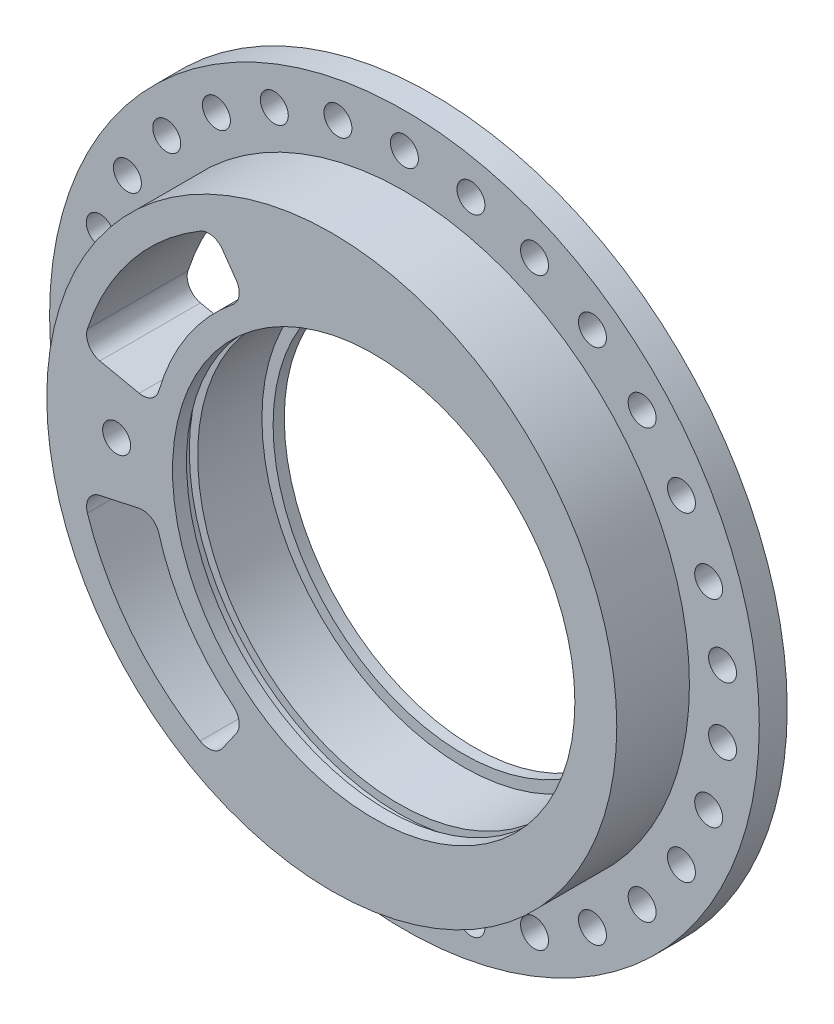
from build123d import *

# Parameters (mm, degrees)
SKETCH1_R           = 63.5
BOSS_EXTRUDE1_DEPTH = 5
SKETCH2_R           = 51
BOSS_EXTRUDE2_DEPTH = 13
SKETCH3_R           = 36
CUT_EXTRUDE1_DEPTH  = 19
CUT_EXTRUDE3_START  = -2.5
SKETCH4_R           = 37.5
SKETCH4_R_2         = 36
CUT_EXTRUDE3_DEPTH  = 2
SKETCH6_R           = 36
SKETCH6_R_2         = 34
BOSS_EXTRUDE6_DEPTH = 2
SKETCH9_R           = 2.5
CUT_EXTRUDE9_DEPTH  = 6
SKETCH10_R          = 2.5
CUT_EXTRUDE10_DEPTH = 19
CUT_EXTRUDE11_DEPTH = 19
FILLET1_R           = 3
FILLET2_R           = 3
FILLET3_R           = 3


with BuildPart() as part:
    # Sketch1 → Boss-Extrude1 (new body)
    with BuildSketch(Plane.XY):
        Circle(SKETCH1_R)
    extrude(amount=BOSS_EXTRUDE1_DEPTH)

    # Sketch2 → Boss-Extrude2 (add)
    with BuildSketch(Plane.XY.offset(5)):
        Circle(SKETCH2_R)
    extrude(amount=BOSS_EXTRUDE2_DEPTH)

    # Sketch3 → Cut-Extrude1 (cut, through all)
    with BuildSketch(Plane.XY.offset(18)):
        with Locations((7.5, 0)):
            Circle(SKETCH3_R)
    extrude(amount=-CUT_EXTRUDE1_DEPTH, mode=Mode.SUBTRACT)

    # Sketch4 → Cut-Extrude3 (cut)
    with BuildSketch(Plane.XY.offset(18).offset(CUT_EXTRUDE3_START)):
        with Locations((7.5, 0)):
            Circle(SKETCH4_R)
        with Locations((7.5, 0)):
            Circle(SKETCH4_R_2, mode=Mode.SUBTRACT)
    extrude(amount=-CUT_EXTRUDE3_DEPTH, mode=Mode.SUBTRACT)

    # Sketch6 → Boss-Extrude6 (add)
    with BuildSketch(Plane(origin=(0, 0, 0), x_dir=(-1, 0, 0), z_dir=(0, 0, -1))):
        with Locations((-7.5, 0)):
            Circle(SKETCH6_R)
        with Locations((-7.5, 0)):
            Circle(SKETCH6_R_2, mode=Mode.SUBTRACT)
    extrude(amount=-BOSS_EXTRUDE6_DEPTH)

    # Sketch9 → Cut-Extrude9 (cut, through all)
    with BuildSketch(Plane.XY.offset(5)):
        with Locations((0, 57.24)):
            Circle(SKETCH9_R)
        with Locations((11.900865182, 55.989168666)):
            Circle(SKETCH9_R)
        with Locations((23.28160545, 52.291341995)):
            Circle(SKETCH9_R)
        with Locations((33.644827841, 46.308132758)):
            Circle(SKETCH9_R)
        with Locations((42.53760981, 38.301035908)):
            Circle(SKETCH9_R)
        with Locations((49.571294113, 28.62)):
            Circle(SKETCH9_R)
        with Locations((54.438474993, 17.688132758)):
            Circle(SKETCH9_R)
        with Locations((56.926433291, 5.983209237)):
            Circle(SKETCH9_R)
        with Locations((56.926433291, -5.983209237)):
            Circle(SKETCH9_R)
        with Locations((54.438474993, -17.688132758)):
            Circle(SKETCH9_R)
        with Locations((49.571294113, -28.62)):
            Circle(SKETCH9_R)
        with Locations((42.53760981, -38.301035908)):
            Circle(SKETCH9_R)
        with Locations((33.644827841, -46.308132758)):
            Circle(SKETCH9_R)
        with Locations((23.28160545, -52.291341995)):
            Circle(SKETCH9_R)
        with Locations((11.900865182, -55.989168666)):
            Circle(SKETCH9_R)
        with Locations((0, -57.24)):
            Circle(SKETCH9_R)
        with Locations((-11.900865182, -55.989168666)):
            Circle(SKETCH9_R)
        with Locations((-23.28160545, -52.291341995)):
            Circle(SKETCH9_R)
        with Locations((-33.644827841, -46.308132758)):
            Circle(SKETCH9_R)
        with Locations((-42.53760981, -38.301035908)):
            Circle(SKETCH9_R)
        with Locations((-49.571294113, -28.62)):
            Circle(SKETCH9_R)
        with Locations((-54.438474993, -17.688132758)):
            Circle(SKETCH9_R)
        with Locations((-56.926433291, -5.983209237)):
            Circle(SKETCH9_R)
        with Locations((-56.926433291, 5.983209237)):
            Circle(SKETCH9_R)
        with Locations((-54.438474993, 17.688132758)):
            Circle(SKETCH9_R)
        with Locations((-49.571294113, 28.62)):
            Circle(SKETCH9_R)
        with Locations((-42.53760981, 38.301035908)):
            Circle(SKETCH9_R)
        with Locations((-33.644827841, 46.308132758)):
            Circle(SKETCH9_R)
        with Locations((-23.28160545, 52.291341995)):
            Circle(SKETCH9_R)
        with Locations((-11.900865182, 55.989168666)):
            Circle(SKETCH9_R)
    extrude(amount=-CUT_EXTRUDE9_DEPTH, mode=Mode.SUBTRACT)

    # Sketch10 → Cut-Extrude10 (cut, through all)
    with BuildSketch(Plane.XY.offset(18)):
        with Locations((-38.5, 0)):
            Circle(SKETCH10_R)
    extrude(amount=-CUT_EXTRUDE10_DEPTH, mode=Mode.SUBTRACT)

    # Sketch11 → Cut-Extrude11 (cut, through all)
    with BuildSketch(Plane.XY.offset(18)):
        with BuildLine():
            ThreePointArc((-15.443057454, 32.766081772), (-25.855432883, 22.077479412), (-31.625904029, 8.316467633))
            Line((-31.625904029, 8.316467633), (-44.644725504, 11.083703562))
            ThreePointArc((-44.644725504, 11.083703562), (-36.095276344, 28.515452402), (-21.115563753, 40.867260336))
            Line((-21.115563753, 40.867260336), (-15.443057454, 32.766081772))
        make_face()
    cut_extrude11 = extrude(amount=-CUT_EXTRUDE11_DEPTH, mode=Mode.SUBTRACT)

    # Mirror1: Cut-Extrude11 across plane
    add(cut_extrude11.mirror(Plane.ZX), mode=Mode.SUBTRACT)

    # Fillet1
    fillet1_edges = [part.edges().sort_by_distance(p)[0] for p in [
        (-44.644725504, 11.083703562, 9),
    ]]
    fillet(fillet1_edges, radius=FILLET1_R)

    # Fillet2
    fillet2_edges = [part.edges().sort_by_distance(p)[0] for p in [
        (-15.443057454, 32.766081772, 9),
        (-31.625904029, 8.316467633, 9),
        (-21.115563753, 40.867260336, 9),
    ]]
    fillet(fillet2_edges, radius=FILLET2_R)

    # Fillet3
    fillet3_edges = [part.edges().sort_by_distance(p)[0] for p in [
        (-31.625904029, -8.316467633, 9),
        (-15.443057454, -32.766081772, 9),
        (-21.115563753, -40.867260336, 9),
        (-44.644725504, -11.083703562, 9),
    ]]
    fillet(fillet3_edges, radius=FILLET3_R)


solid = part.part
